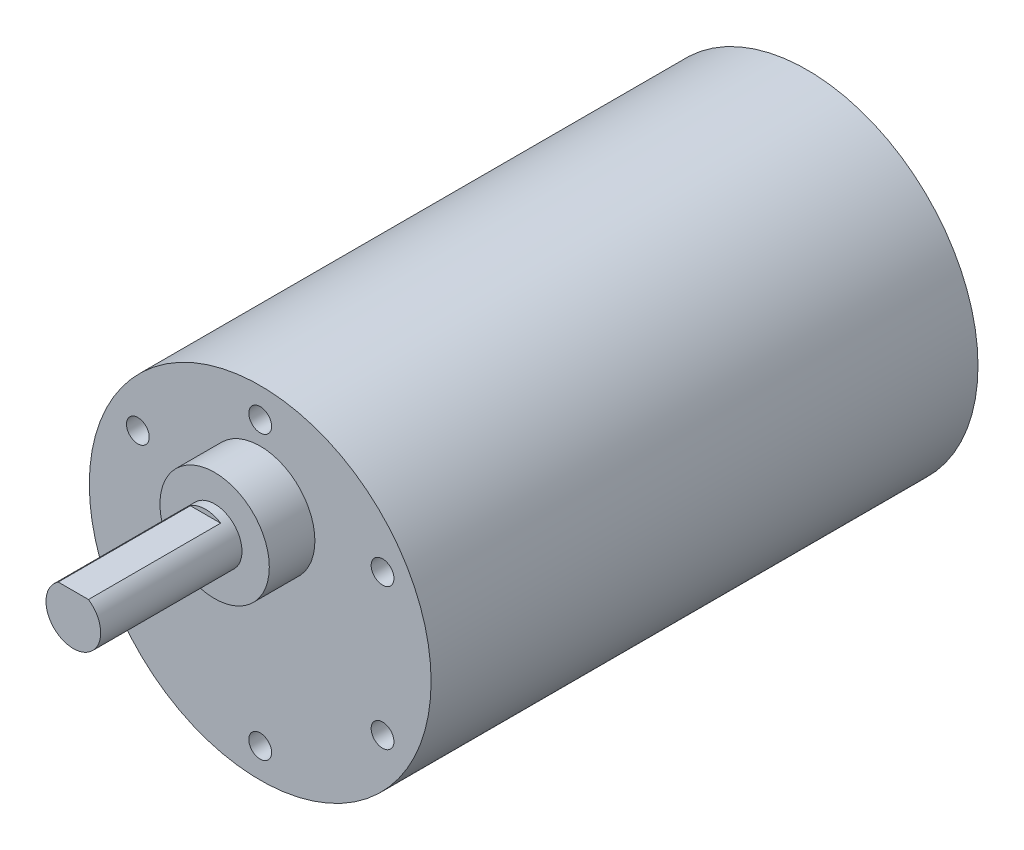
from build123d import *

# Parameters (mm, degrees)
SKETCH_1_R               = 18.75
EXTRUDE_1_DEPTH          = 60
SKETCH_2_R               = 6
EXTRUDE_2_DEPTH          = 5
SKETCH_3_R               = 3
EXTRUDE_3_DEPTH          = 15.5
SKETCH_4_W               = 7.331861777
SKETCH_4_H               = 1.908292791
CUT_EXTRUDE_1_DEPTH      = 14.5
PATTERN_CIRCULAR_1_COUNT = 6


with BuildPart() as part:
    # 草图1 → 凸台-拉伸1 (new body)
    with BuildSketch(Plane.XY):
        Circle(SKETCH_1_R)
    extrude(amount=EXTRUDE_1_DEPTH)

    # 草图2 → 凸台-拉伸2 (add)
    with BuildSketch(Plane.XY.offset(60)):
        with Locations((0, 7)):
            Circle(SKETCH_2_R)
    extrude(amount=EXTRUDE_2_DEPTH)

    # 草图3 → 凸台-拉伸3 (add)
    with BuildSketch(Plane.XY.offset(65)):
        with Locations((0, 7)):
            Circle(SKETCH_3_R)
    extrude(amount=EXTRUDE_3_DEPTH)

    # 草图4 → 切除-拉伸1 (cut)
    with BuildSketch(Plane.XY.offset(80.5)):
        with Locations((-0.04202298, 10.454146396)):
            Rectangle(SKETCH_4_W, SKETCH_4_H)
    extrude(amount=-CUT_EXTRUDE_1_DEPTH, mode=Mode.SUBTRACT)

    # 草图6 → M3 螺纹孔1 (revolve, cut)
    with BuildSketch(Plane(origin=(0, 15.5, 60), x_dir=(0, -1, 0), z_dir=(1, 0, 0))):
        Polygon((0, 0), (0, 8.251075774), (1.25, 7.5), (1.25, 0), align=None)
    hole_wizard_m3_1 = revolve(axis=Axis((0, 15.5, 66.35), (0, 0, -1)), mode=Mode.SUBTRACT)

    # 阵列(圆周)1: M3 螺纹孔1 ×6 about axis
    pattern_circular_1_axis = Axis((0, 0, 0), (0, 0, 1))
    for i in range(1, PATTERN_CIRCULAR_1_COUNT):
        add(hole_wizard_m3_1.rotate(pattern_circular_1_axis, i * 360 / PATTERN_CIRCULAR_1_COUNT), mode=Mode.SUBTRACT)


solid = part.part
